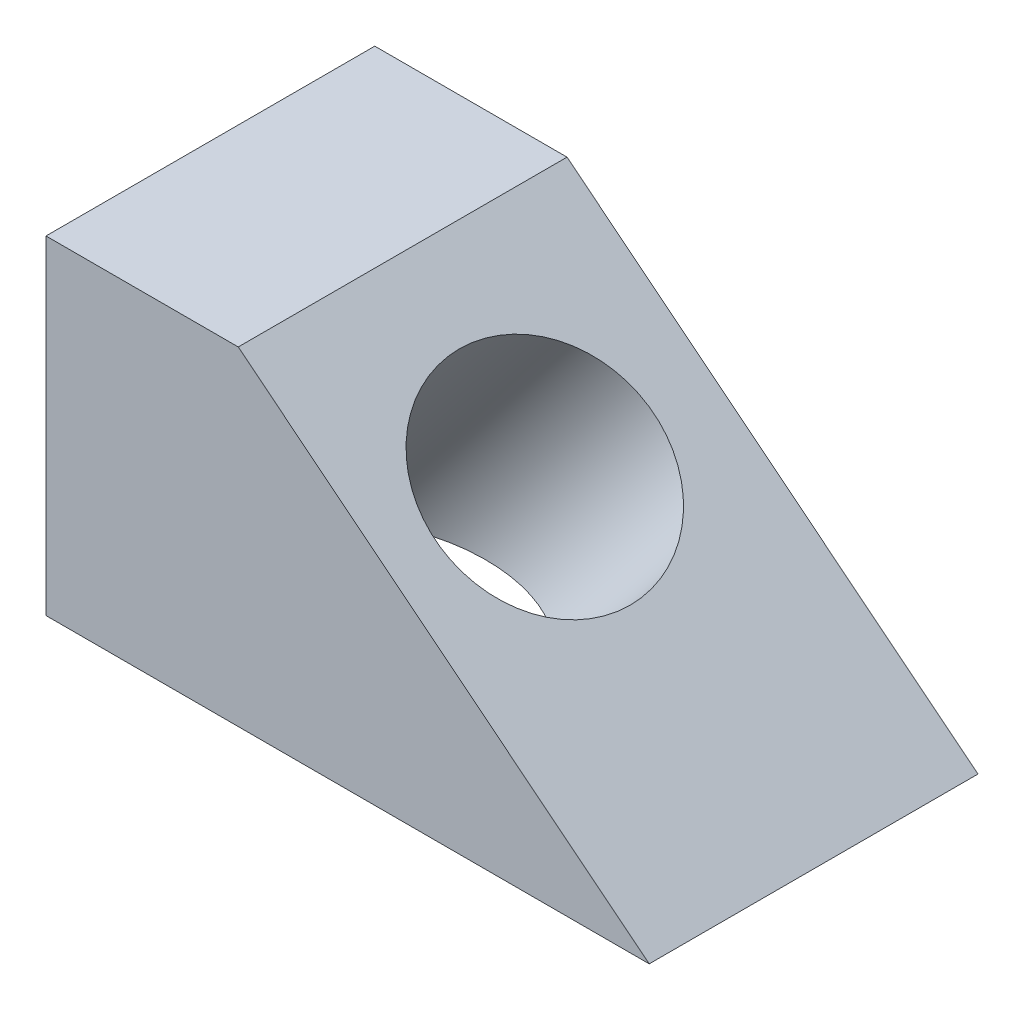
from build123d import *

# Parameters (mm, degrees)
BOSS_EXTRUDE1_DEPTH = 29.972
CUT_EXTRUDE1_REACH  = 70.705
SKETCH2_R           = 19.939


with BuildPart() as part:
    # Sketch1 → Boss-Extrude1 (new body, symmetric)
    with BuildSketch(Plane.XY):
        Polygon((0, 0), (0, 59.944), (35.052, 59.944), (109.982, 0), align=None)
    extrude(amount=BOSS_EXTRUDE1_DEPTH, both=True)

    # Cut-Extrude1: up to this face of the body (flat: up to its plane)
    cut_extrude1_end = Plane(part.part.faces().sort_by_distance((54.991, 0, 0))[0])
    # Sketch2 → Cut-Extrude1 (cut, up to the picked face)
    with BuildSketch(Plane(origin=(42.919804878, 53.649756098, 0), x_dir=(0.780868809, -0.624695048, 0), z_dir=(0.624695048, 0.780868809, 0)), mode=Mode.PRIVATE) as cut_extrude1_sk1:
        with Locations((24.4135134, -1.016)):
            Circle(SKETCH2_R)
    cut_extrude1_tool1 = split(extrude(cut_extrude1_sk1.sketch, amount=-CUT_EXTRUDE1_REACH, mode=Mode.PRIVATE), bisect_by=cut_extrude1_end, keep=Keep.BOTH, mode=Mode.PRIVATE)
    add(cut_extrude1_tool1.solids().sort_by_distance((61.983556, 38.398755, 1.016))[0], mode=Mode.SUBTRACT)


solid = part.part
